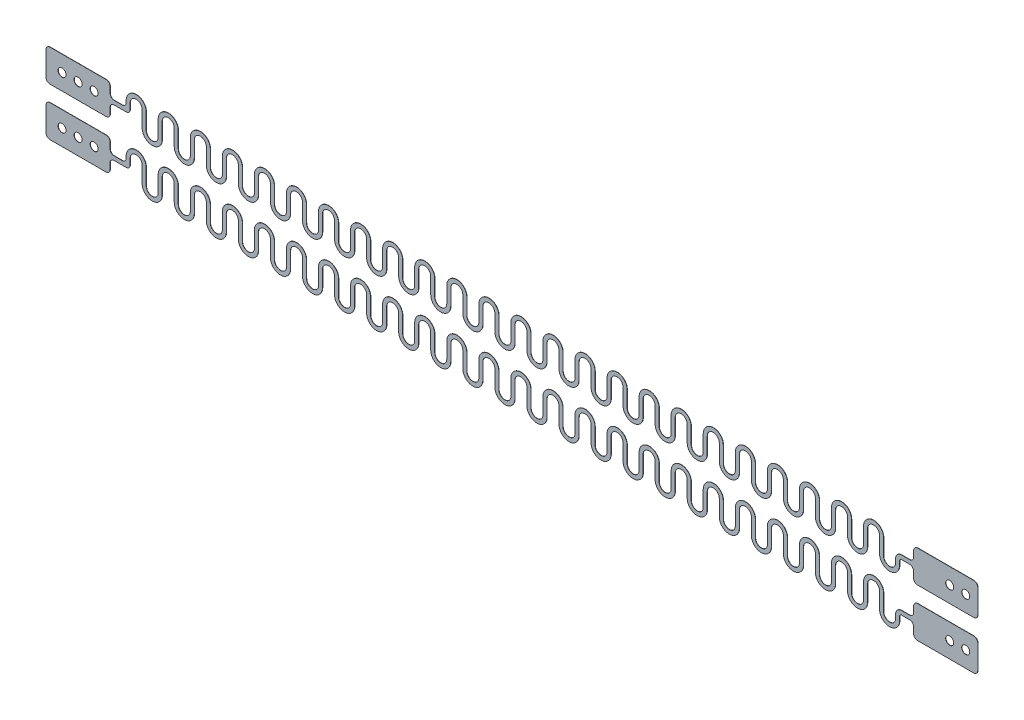
from build123d import *

# Parameters (mm, degrees)
SKETCH1_W             = 4
SKETCH1_H             = 2
BOSS_EXTRUDE2_DEPTH   = 0.015
BOSS_EXTRUDE2_2_DEPTH = 0.015
BOSS_EXTRUDE4_DEPTH   = 0.015
FILLET1_R             = 0.25
SKETCH5_R             = 0.25
CUT_EXTRUDE1_DEPTH    = 1.015
SKETCH7_W             = 0.125
SKETCH7_H             = 0.5
BOSS_EXTRUDE9_DEPTH   = 0.015
FILLET2_R             = 0.25
SKETCH8_R             = 0.25
CUT_EXTRUDE2_DEPTH    = 1.015
BOSS_EXTRUDE10_DEPTH  = 0.015
BOSS_EXTRUDE16_DEPTH  = 0.015
LPATTERN3_COUNT       = 23
LPATTERN3_PITCH       = 2
SKETCH15_W            = 4
SKETCH15_H            = 2
BOSS_EXTRUDE17_DEPTH  = 0.015
FILLET3_R             = 0.25
SKETCH16_W            = 4
SKETCH16_H            = 2
BOSS_EXTRUDE18_DEPTH  = 0.015
FILLET4_R             = 0.25
SKETCH17_R            = 0.25
CUT_EXTRUDE3_DEPTH    = 1.015


with BuildPart() as part:
    # Sketch1 → Boss-Extrude2 (new body)
    with BuildSketch(Plane.XY):
        with Locations((0, 1.5)):
            Rectangle(SKETCH1_W, SKETCH1_H)
    extrude(amount=BOSS_EXTRUDE2_DEPTH)

    # Sketch7 → Boss-Extrude9 (add)
    with BuildSketch(Plane.XY):
        with BuildLine():
            Line((-2, 1.625), (-2.75, 1.625))
            ThreePointArc((-2.75, 1.625), (-3.015165043, 1.515165043), (-3.125, 1.25))
            Line((-3.125, 1.25), (-3.125, 1))
            ThreePointArc((-3.125, 1), (-3.5, 0.625), (-3.875, 1))
            Line((-3.875, 1), (-3.875, 2))
            ThreePointArc((-3.875, 2), (-4.5, 2.625), (-5.125, 2))
            Line((-5.125, 2), (-4.875, 2))
            ThreePointArc((-4.875, 2), (-4.5, 2.375), (-4.125, 2))
            Line((-4.125, 2), (-4.125, 1))
            ThreePointArc((-4.125, 1), (-3.5, 0.375), (-2.875, 1))
            Line((-2.875, 1), (-2.875, 1.25))
            ThreePointArc((-2.875, 1.25), (-2.838388348, 1.338388348), (-2.75, 1.375))
            Line((-2.75, 1.375), (-2, 1.375))
            Line((-2, 1.375), (-2, 1.625))
        make_face()
        with Locations((-5.0625, 1.75)):
            Rectangle(SKETCH7_W, SKETCH7_H)
        with Locations((-4.9375, 1.75)):
            Rectangle(SKETCH7_W, SKETCH7_H)
    extrude(amount=BOSS_EXTRUDE9_DEPTH)

    # Fillet2
    fillet2_edges = [part.edges().sort_by_distance(p)[0] for p in [
        (-2, 1.375, 0.0075),
        (-2, 1.625, 0.0075),
        (2, 0.5, 0.0075),
        (-2, 0.5, 0.0075),
        (-2, 2.5, 0.0075),
        (2, 2.5, 0.0075),
    ]]
    fillet(fillet2_edges, radius=FILLET2_R)

    # Sketch8 → Cut-Extrude2 (cut, through all)
    with BuildSketch(Plane.XY.offset(0.015)):
        with Locations((1.25, 1.5)):
            Circle(SKETCH8_R)
        with Locations((0.25, 1.5)):
            Circle(SKETCH8_R)
    extrude(amount=-CUT_EXTRUDE2_DEPTH, mode=Mode.SUBTRACT)

    # Sketch14 → Boss-Extrude16 (add)
    with BuildSketch(Plane.XY.offset(0.015)):
        with BuildLine():
            Line((-6.875, 2), (-6.875, 1.5))
            Line((-6.875, 1.5), (-7.125, 1.5))
            Line((-7.125, 1.5), (-7.125, 2))
            ThreePointArc((-7.125, 2), (-6.5, 2.625), (-5.875, 2))
            Line((-5.875, 2), (-5.875, 1))
            ThreePointArc((-5.875, 1), (-5.5, 0.625), (-5.125, 1))
            Line((-5.125, 1), (-5.125, 1.5))
            Line((-5.125, 1.5), (-4.875, 1.5))
            Line((-4.875, 1.5), (-4.875, 1))
            ThreePointArc((-4.875, 1), (-5.5, 0.375), (-6.125, 1))
            Line((-6.125, 1), (-6.125, 2))
            ThreePointArc((-6.125, 2), (-6.5, 2.375), (-6.875, 2))
        make_face()
    boss_extrude16 = extrude(amount=-BOSS_EXTRUDE16_DEPTH)


with BuildPart() as body_2:
    # Sketch1 → Boss-Extrude2 2 (new body)
    with BuildSketch(Plane.XY):
        with Locations((0, -1.5)):
            Rectangle(SKETCH1_W, SKETCH1_H)
    extrude(amount=BOSS_EXTRUDE2_2_DEPTH)

    # Sketch4 → Boss-Extrude4 (add)
    with BuildSketch(Plane.XY):
        with BuildLine():
            Line((-2, -1.625), (-2, -1.375))
            Line((-2, -1.375), (-2.75, -1.375))
            ThreePointArc((-2.75, -1.375), (-3.015165043, -1.484834957), (-3.125, -1.75))
            Line((-3.125, -1.75), (-3.125, -2))
            ThreePointArc((-3.125, -2), (-3.5, -2.375), (-3.875, -2))
            Line((-3.875, -2), (-3.875, -1))
            ThreePointArc((-3.875, -1), (-4.5, -0.375), (-5.125, -1))
            Line((-5.125, -1), (-5.125, -1.5))
            Line((-5.125, -1.5), (-4.875, -1.5))
            Line((-4.875, -1.5), (-4.875, -1))
            ThreePointArc((-4.875, -1), (-4.5, -0.625), (-4.125, -1))
            Line((-4.125, -1), (-4.125, -2))
            ThreePointArc((-4.125, -2), (-3.5, -2.625), (-2.875, -2))
            Line((-2.875, -2), (-2.875, -1.75))
            ThreePointArc((-2.875, -1.75), (-2.838388348, -1.661611652), (-2.75, -1.625))
            Line((-2.75, -1.625), (-2, -1.625))
        make_face()
    extrude(amount=BOSS_EXTRUDE4_DEPTH)

    # Fillet1
    fillet1_edges = [body_2.edges().sort_by_distance(p)[0] for p in [
        (-2, -1.625, 0.0075),
        (-2, -1.375, 0.0075),
        (2, -2.5, 0.0075),
        (-2, -2.5, 0.0075),
        (-2, -0.5, 0.0075),
        (2, -0.5, 0.0075),
    ]]
    fillet(fillet1_edges, radius=FILLET1_R)

    # Sketch5 → Cut-Extrude1 (cut, through all)
    with BuildSketch(Plane.XY.offset(0.015)):
        with Locations((1.25, -1.5)):
            Circle(SKETCH5_R)
        with Locations((0.25, -1.5)):
            Circle(SKETCH5_R)
    extrude(amount=-CUT_EXTRUDE1_DEPTH, mode=Mode.SUBTRACT)

    # Sketch9 → Boss-Extrude10 (add)
    with BuildSketch(Plane.XY):
        with BuildLine():
            Line((-4.875, -1.5), (-5.125, -1.5))
            Line((-5.125, -1.5), (-5.125, -2))
            ThreePointArc((-5.125, -2), (-5.5, -2.375), (-5.875, -2))
            Line((-5.875, -2), (-5.875, -1))
            ThreePointArc((-5.875, -1), (-6.5, -0.375), (-7.125, -1))
            Line((-7.125, -1), (-7.125, -1.5))
            Line((-7.125, -1.5), (-6.875, -1.5))
            Line((-6.875, -1.5), (-6.875, -1))
            ThreePointArc((-6.875, -1), (-6.5, -0.625), (-6.125, -1))
            Line((-6.125, -1), (-6.125, -2))
            ThreePointArc((-6.125, -2), (-5.5, -2.625), (-4.875, -2))
            Line((-4.875, -2), (-4.875, -1.5))
        make_face()
    boss_extrude10 = extrude(amount=BOSS_EXTRUDE10_DEPTH)


with BuildPart() as part_1:
    add(part.part)

    add(body_2.part)  # LPattern3 merges body 2
    # LPattern3: Boss-Extrude10, Boss-Extrude16 ×23
    with Locations(*[(-i * LPATTERN3_PITCH, 0, 0) for i in range(1, LPATTERN3_COUNT)]):
        add(boss_extrude10)
        add(boss_extrude16)

    # Sketch15 → Boss-Extrude17 (add)
    with BuildSketch(Plane.XY.offset(0.015)):
        with Locations((-54.125, -1.5)):
            Rectangle(SKETCH15_W, SKETCH15_H)
        Polygon((-51.125, -1.5), (-51.125, -1.375), (-52.125, -1.375), (-52.125, -1.625), (-51.125, -1.625), (-50.875, -1.625), (-50.875, -1.5), align=None)
    extrude(amount=-BOSS_EXTRUDE17_DEPTH)

    # Fillet3
    fillet3_edges = [part_1.edges().sort_by_distance(p)[0] for p in [
        (-52.125, -1.625, 0.0075),
        (-50.875, -1.625, 0.0075),
        (-51.125, -1.375, 0.0075),
        (-52.125, -1.375, 0.0075),
        (-52.125, -0.5, 0.0075),
        (-56.125, -0.5, 0.0075),
        (-56.125, -2.5, 0.0075),
        (-52.125, -2.5, 0.0075),
    ]]
    fillet(fillet3_edges, radius=FILLET3_R)

    # Sketch16 → Boss-Extrude18 (add)
    with BuildSketch(Plane.XY.offset(0.015)):
        with Locations((-54.125, 1.5)):
            Rectangle(SKETCH16_W, SKETCH16_H)
        Polygon((-51.125, 1.5), (-51.125, 1.625), (-52.125, 1.625), (-52.125, 1.375), (-51.125, 1.375), (-50.875, 1.375), (-50.875, 1.5), align=None)
    extrude(amount=-BOSS_EXTRUDE18_DEPTH)

    # Fillet4
    fillet4_edges = [part_1.edges().sort_by_distance(p)[0] for p in [
        (-52.125, 1.375, 0.0075),
        (-50.875, 1.375, 0.0075),
        (-51.125, 1.625, 0.0075),
        (-52.125, 1.625, 0.0075),
        (-52.125, 2.5, 0.0075),
        (-56.125, 2.5, 0.0075),
        (-56.125, 0.5, 0.0075),
        (-52.125, 0.5, 0.0075),
    ]]
    fillet(fillet4_edges, radius=FILLET4_R)

    # Sketch17 → Cut-Extrude3 (cut, through all)
    with BuildSketch(Plane.XY.offset(0.015)):
        with Locations((-55.125, 1.5)):
            Circle(SKETCH17_R)
        with Locations((-54.125, 1.5)):
            Circle(SKETCH17_R)
        with Locations((-53.125, 1.5)):
            Circle(SKETCH17_R)
        with Locations((-54.125, -1.5)):
            Circle(SKETCH17_R)
        with Locations((-53.125, -1.5)):
            Circle(SKETCH17_R)
        with Locations((-55.125, -1.5)):
            Circle(SKETCH17_R)
    extrude(amount=-CUT_EXTRUDE3_DEPTH, mode=Mode.SUBTRACT)


solid = part_1.part
